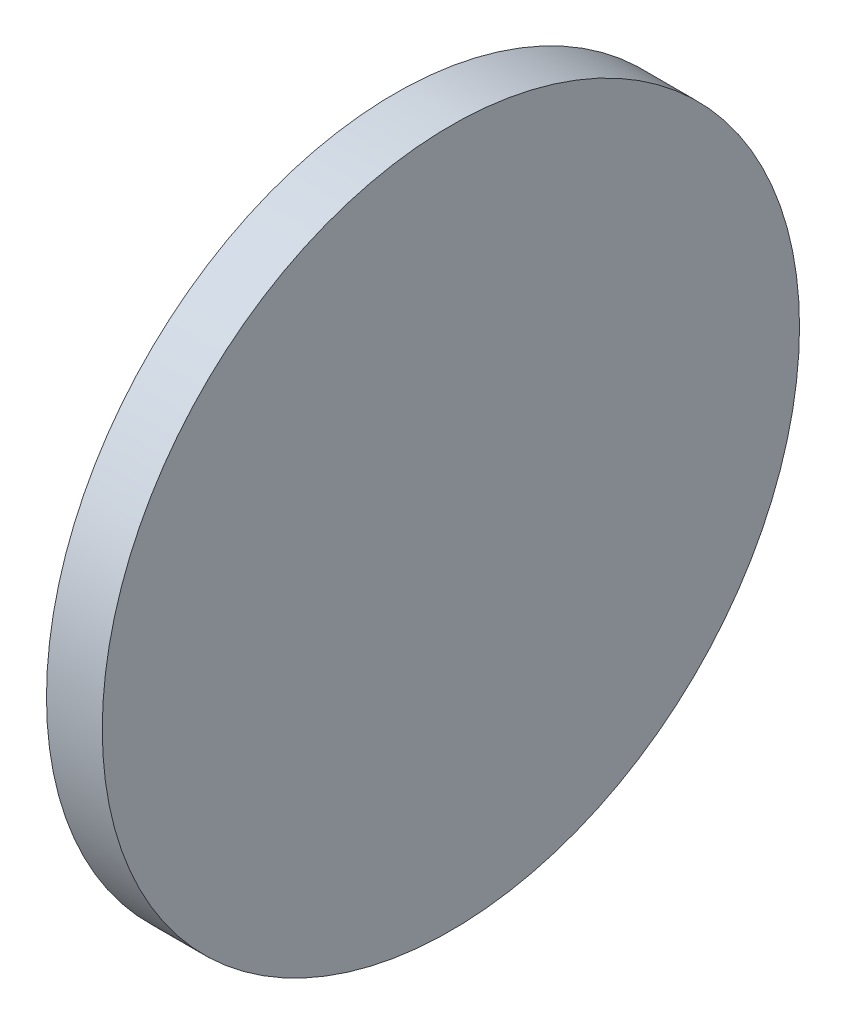
from build123d import *

# Parameters (mm, degrees)
SKETCH_1_W = 4
SKETCH_1_H = 25


with BuildPart() as part:
    # 草图1 → 旋转1 (revolve)
    with BuildSketch(Plane.XY, mode=Mode.PRIVATE) as revolve_1_sk:
        with Locations((522.369723166, 167.086358698)):
            Rectangle(SKETCH_1_W, SKETCH_1_H)
    revolve(revolve_1_sk.sketch.rotate(Axis((500.737567697, 154.586358698, 0), (1, 0, 0)), 90), axis=Axis((500.737567697, 154.586358698, 0), (1, 0, 0)))  # turned: the seam where the file's is


solid = part.part
